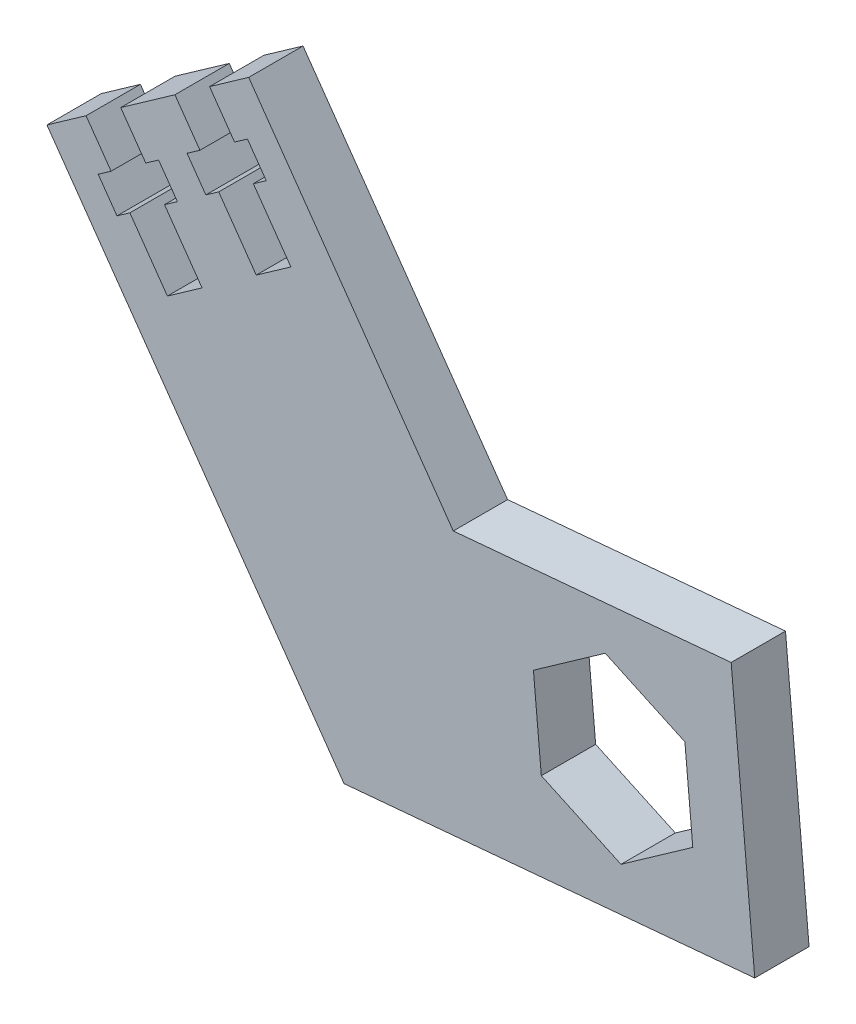
from build123d import *

# Parameters (mm, degrees)
BOSS_EXTRUDE1_DEPTH = 5


with BuildPart() as part:
    # Sketch3 → Boss-Extrude1 (new body)
    with BuildSketch(Plane.XY.offset(4.376601216)):
        Polygon((-41.095887165, 37.669622361), (-13.754633765, -1.155465661), (24.040364141, 2.253439084), (21.87007244, 26.315763035), (-3.700822745, 24.009406354), (-22.528508458, 50.745070018), (-26.12981396, 48.208972579), (-23.826719635, 44.93853583), (-22.641186314, 45.773407523), (-20.91386557, 43.320579961), (-22.099398891, 42.485708268), (-18.644757404, 37.580053144), (-21.833433235, 35.334536178), (-25.288074722, 40.240191301), (-26.473608044, 39.405319609), (-28.200928787, 41.85814717), (-27.015395466, 42.693018863), (-29.318489791, 45.963455612), (-34.305905833, 42.451236767), (-32.002811508, 39.180800018), (-30.817278187, 40.015671711), (-29.089957443, 37.562844149), (-30.275490764, 36.727972456), (-26.820849277, 31.822317332), (-30.009525108, 29.576800365), (-33.464166595, 34.482455489), (-34.649699917, 33.647583796), (-36.37702066, 36.100411358), (-35.191487339, 36.935283051), (-37.494581664, 40.2057198), align=None)
        Polygon((3.674129189, 16.601950475), (4.399955221, 8.554616968), (11.732063487, 5.159533997), (18.338345721, 9.811784534), (17.612519688, 17.859118041), (10.280411422, 21.254201011), align=None, mode=Mode.SUBTRACT)
    extrude(amount=-BOSS_EXTRUDE1_DEPTH)


solid = part.part
